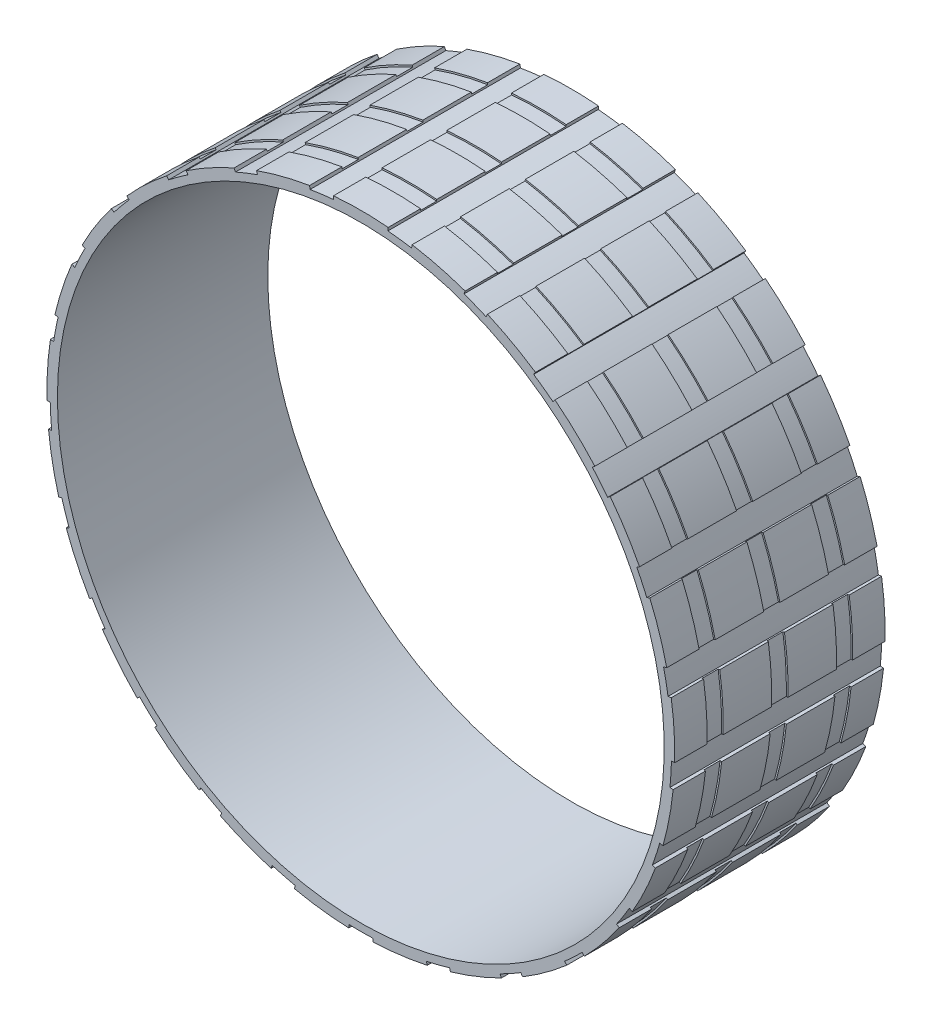
from build123d import *

# Parameters (mm, degrees)
SKETCH2_R                      = 19.2
BOSS_EXTRUDE1_DEPTH            = 6.5
CUT_EXTRUDE1_REACH             = 29.92
SKETCH1_R                      = 18.75
CUT_EXTRUDE1_DIRECTION_2_REACH = 29.92
REVOLVE1_ANGLE                 = 10
CIRPATTERN1_COUNT              = 25


with BuildPart() as part:
    # Sketch2 → Boss-Extrude1 (new, symmetric)
    with BuildSketch(Plane.XY):
        with Locations(Location((0, 0, 0), (0, 0, 180))):
            Circle(SKETCH2_R)
    extrude(amount=BOSS_EXTRUDE1_DEPTH, both=True)

    # Sketch1 → Cut-Extrude1 (cut, up to next)
    with BuildSketch(Plane.XY, mode=Mode.PRIVATE) as cut_extrude1_sk1:
        with Locations(Location((0, 0, 0), (0, 0, 180))):
            Circle(SKETCH1_R)
    cut_extrude1_tool1 = extrude(cut_extrude1_sk1.sketch, amount=-CUT_EXTRUDE1_REACH, mode=Mode.PRIVATE) & part.part
    add(cut_extrude1_tool1.solids().sort_by_distance((0, 0, 0))[0], mode=Mode.SUBTRACT)

    # Sketch1 → Cut-Extrude1 direction 2 (cut, up to next)
    with BuildSketch(Plane.XY, mode=Mode.PRIVATE) as cut_extrude1_direction_2_sk1:
        with Locations(Location((0, 0, 0), (0, 0, 180))):
            Circle(SKETCH1_R)
    cut_extrude1_direction_2_tool1 = extrude(cut_extrude1_direction_2_sk1.sketch, amount=CUT_EXTRUDE1_DIRECTION_2_REACH, mode=Mode.PRIVATE) & part.part
    add(cut_extrude1_direction_2_tool1.solids().sort_by_distance((0, 0, 0))[0], mode=Mode.SUBTRACT)

    # Sketch3 → Revolve1 (revolve, symmetric)
    with BuildSketch(Plane(origin=(0, 0, 0), x_dir=(0, 0, -1), z_dir=(1, 0, 0))) as revolve1_sk:
        Polygon((6.5, 19.2), (6.5, 19.4), (4.5, 19.4), (4.5, 19.3), (3.5, 19.3), (3.5, 19.4), (0.5, 19.4), (0.5, 19.3), (-0.5, 19.3), (-0.5, 19.4), (-3.5, 19.4), (-3.5, 19.3), (-4.5, 19.3), (-4.5, 19.4), (-6.5, 19.4), (-6.5, 19.2), align=None)
    revolve1 = revolve(axis=Axis((0, 0, 15.36764193), (0, 0, -1)), revolution_arc=REVOLVE1_ANGLE / 2)
    revolve1 = revolve1 + revolve(revolve1_sk.sketch, axis=Axis((0, 0, 15.36764193), (0, 0, 1)), revolution_arc=REVOLVE1_ANGLE / 2)

    # CirPattern1: Revolve1 ×25 about axis
    cirpattern1_axis = Axis((0, 0, 0), (0, 0, 1))
    for i in range(1, CIRPATTERN1_COUNT):
        add(revolve1.rotate(cirpattern1_axis, i * 360 / CIRPATTERN1_COUNT))


solid = part.part
